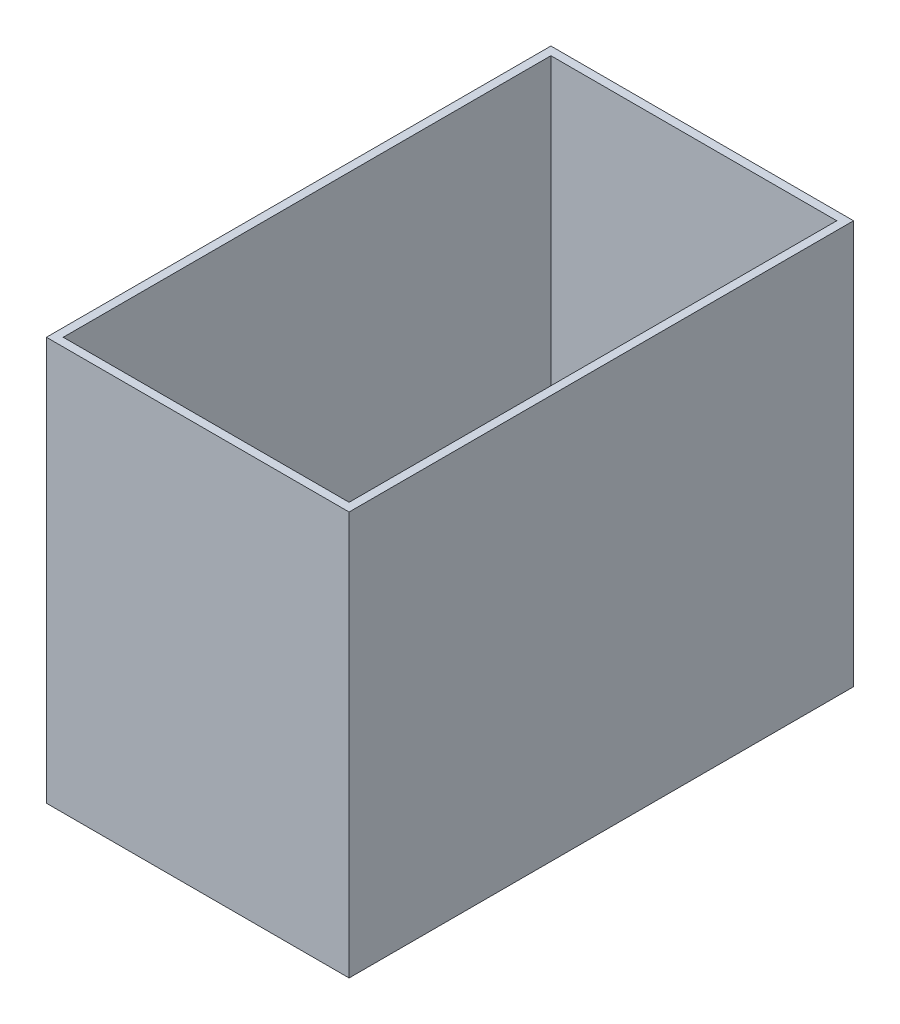
from build123d import *

# Parameters (mm, degrees)
SKETCH1_W           = 228.6
SKETCH1_H           = 381
BOSS_EXTRUDE1_DEPTH = 304.8
SKETCH2_W           = 215.9
SKETCH2_H           = 368.3
CUT_EXTRUDE1_DEPTH  = 298.45


with BuildPart() as part:
    # Sketch1 → Boss-Extrude1 (new body)
    with BuildSketch(Plane(origin=(0, 0, 0), x_dir=(1, 0, 0), z_dir=(0, 1, 0))):
        with Locations((114.3, 190.5)):
            Rectangle(SKETCH1_W, SKETCH1_H)
    extrude(amount=BOSS_EXTRUDE1_DEPTH)

    # Sketch2 → Cut-Extrude1 (cut)
    with BuildSketch(Plane(origin=(0, 304.8, 0), x_dir=(1, 0, 0), z_dir=(0, 1, 0))):
        with Locations((114.3, 190.5)):
            Rectangle(SKETCH2_W, SKETCH2_H)
    extrude(amount=-CUT_EXTRUDE1_DEPTH, mode=Mode.SUBTRACT)


solid = part.part
